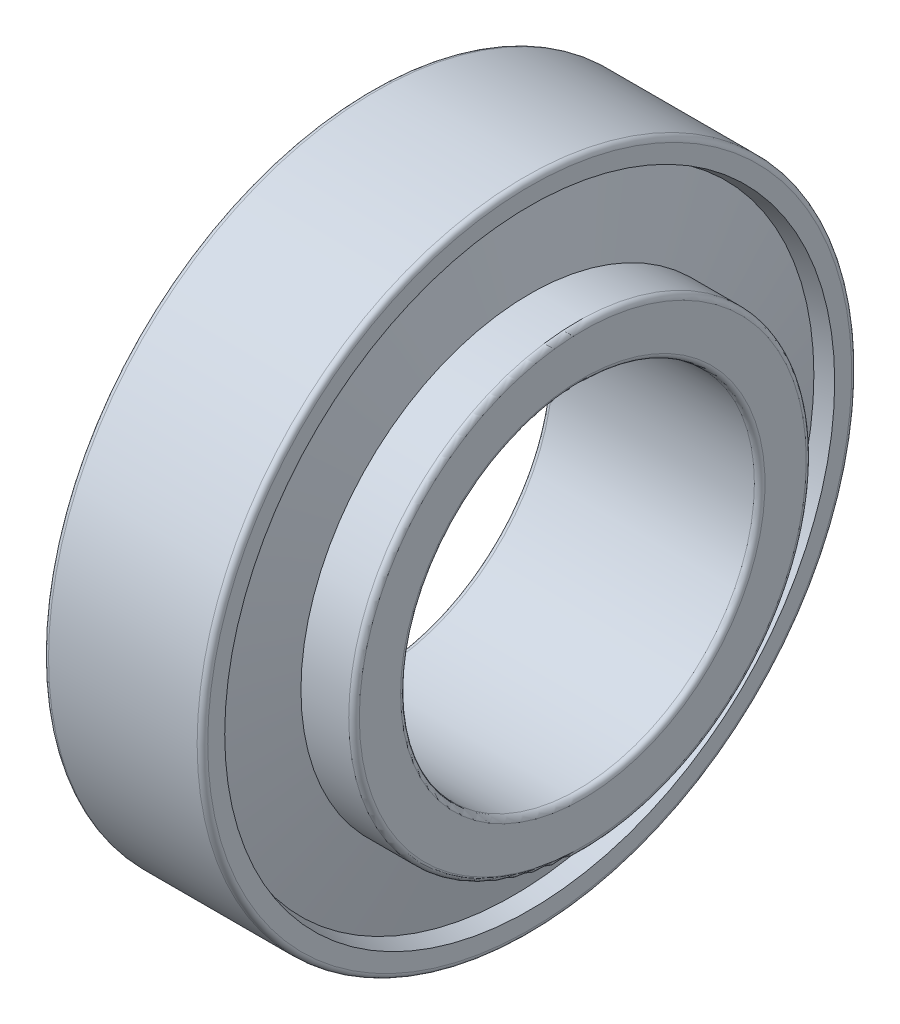
from build123d import *


with BuildPart() as part:
    # Эскиз1 → Повернуть1 (revolve)
    with BuildSketch(Plane.XY):
        with BuildLine():
            Line((0.755685064, 15.014514004), (0, 14.8105))
            Line((0, 14.8105), (0, 18.2))
            ThreePointArc((0, 18.2), (0.087867966, 18.412132034), (0.3, 18.5))
            Line((0.3, 18.5), (8.7, 18.5))
            ThreePointArc((8.7, 18.5), (8.912132034, 18.412132034), (9, 18.2))
            Line((9, 18.2), (9, 17.240250337))
            Line((9, 17.240250337), (8.073423296, 16.990100331))
            Line((8.073423296, 16.990100331), (9, 12.630899669))
            Line((9, 12.630899669), (9, 12.930899669))
            Line((9, 12.930899669), (11.7, 12.930899669))
            ThreePointArc((11.7, 12.930899669), (11.912132034, 12.843031704), (12, 12.630899669))
            Line((12, 12.630899669), (12, 10.3))
            ThreePointArc((12, 10.3), (11.912132034, 10.087867966), (11.7, 10))
            Line((11.7, 10), (0.3, 10))
            ThreePointArc((0.3, 10), (0.087867966, 10.087867966), (0, 10.3))
            Line((0, 10.3), (0, 11.459295301))
            Line((0, 11.459295301), (1.511370127, 11.459295301))
            Line((1.511370127, 11.459295301), (0.755685064, 15.014514004))
        make_face()
    revolve(axis=Axis((-882.527700014, 0, 0), (1, 0, 0)))


solid = part.part
